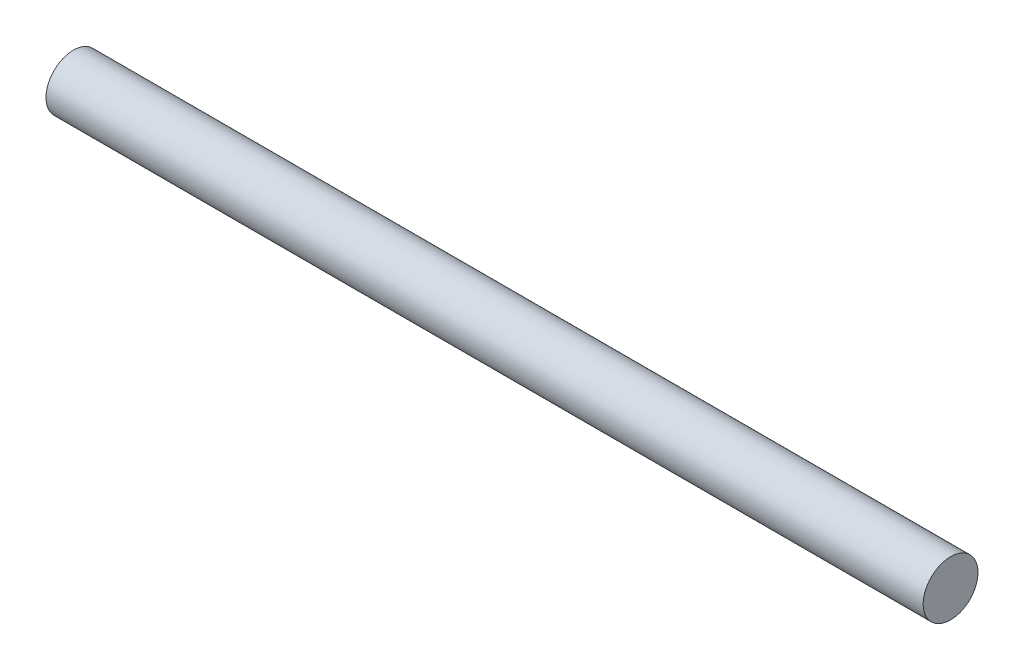
from build123d import *

# Parameters (mm, degrees)
SKETCH1_R           = 3.175
BOSS_EXTRUDE1_DEPTH = 101.6


with BuildPart() as part:
    # Sketch1 → Boss-Extrude1 (new body)
    with BuildSketch(Plane(origin=(0, 0, 0), x_dir=(0, 0, -1), z_dir=(1, 0, 0))):
        Circle(SKETCH1_R)
    extrude(amount=BOSS_EXTRUDE1_DEPTH)


solid = part.part
